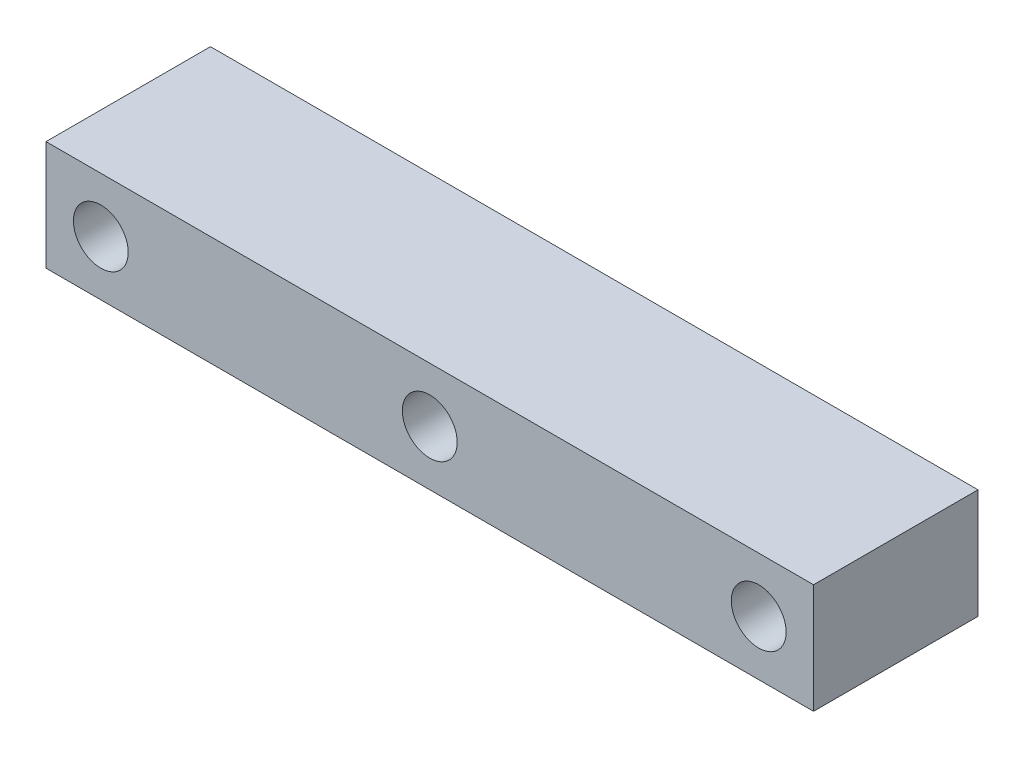
from build123d import *

# Parameters (mm, degrees)
SKETCH1_W           = 177.8
SKETCH1_H           = 25.4
SKETCH1_R           = 6.35
BOSS_EXTRUDE1_DEPTH = 38.1


with BuildPart() as part:
    # Sketch1 → Boss-Extrude1 (new body)
    with BuildSketch(Plane.XY):
        Rectangle(SKETCH1_W, SKETCH1_H)
        with Locations((-76.2, 0)):
            Circle(SKETCH1_R, mode=Mode.SUBTRACT)
        Circle(SKETCH1_R, mode=Mode.SUBTRACT)
        with Locations((76.2, 0)):
            Circle(SKETCH1_R, mode=Mode.SUBTRACT)
    extrude(amount=BOSS_EXTRUDE1_DEPTH)


solid = part.part
